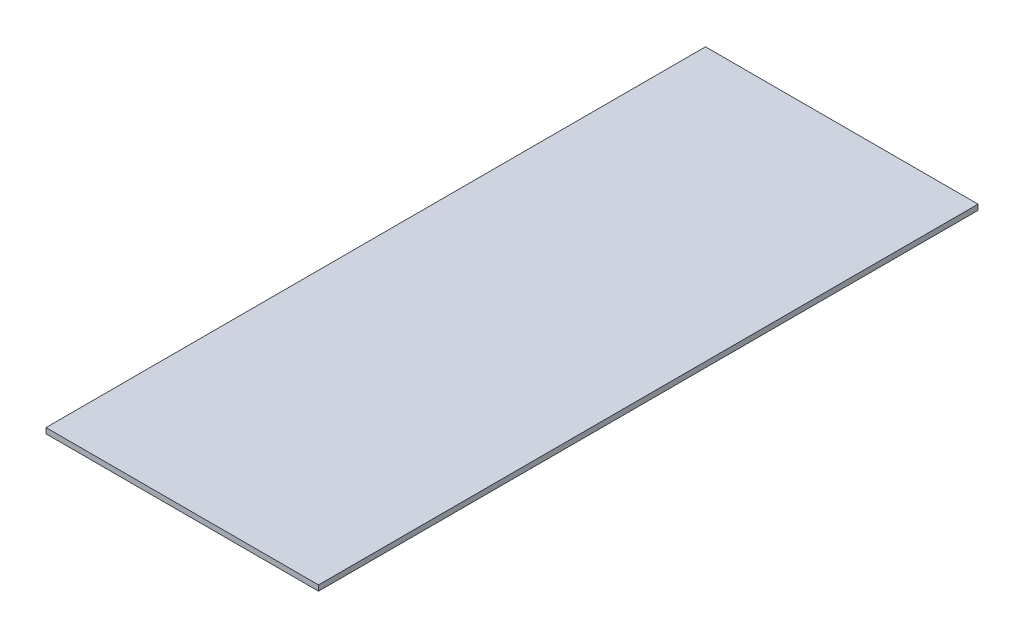
from build123d import *

# Parameters (mm, degrees)
EXTRUDE_1_DEPTH = 2


with BuildPart() as part:
    # 草图2 → 凸台-拉伸1 (new body)
    with BuildSketch(Plane(origin=(0, 0, 0), x_dir=(1, 0, 0), z_dir=(0, 1, 0))):
        Polygon((0, 121), (50, 121), (50, -121), (-50, -121), (-50, 121), align=None)
    extrude(amount=EXTRUDE_1_DEPTH)


solid = part.part
